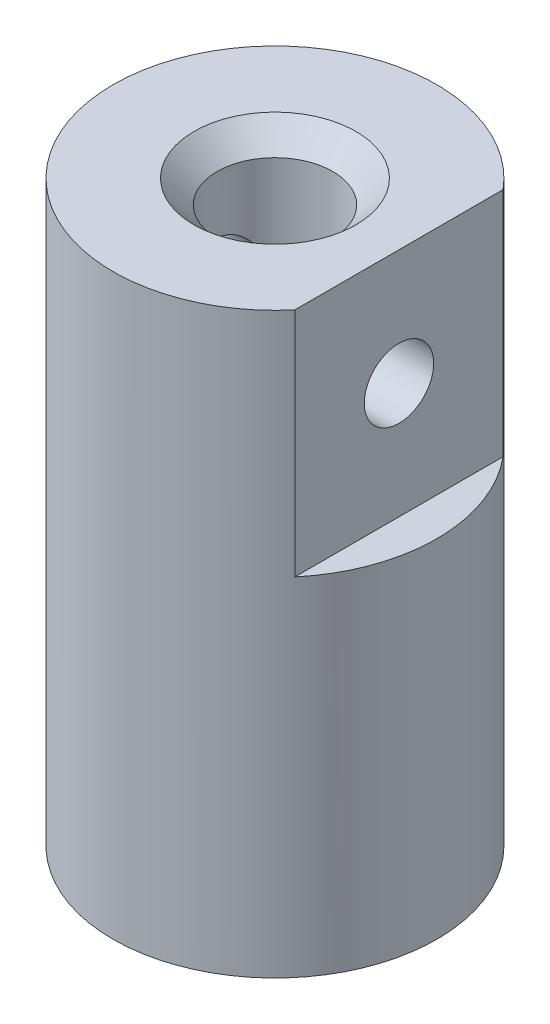
from build123d import *

# Parameters (mm, degrees)
ESQUISSE1_R             = 7
BOSS_EXTRU_1_DEPTH      = 25
ENL_V_MAT_EXTRU_1_REACH = 27
ESQUISSE2_R             = 2.5
CHANFREIN1_SIZE         = 0.5
CHANFREIN2_SIZE         = 1
ENL_V_MAT_EXTRU_2_DEPTH = 10
ESQUISSE4_R             = 1.5
ENL_V_MAT_EXTRU_3_DEPTH = 13.361902647


with BuildPart() as part:
    # Esquisse1 → Boss.-Extru.1 (new body)
    with BuildSketch(Plane(origin=(0, 0, 0), x_dir=(1, 0, 0), z_dir=(0, 1, 0))):
        Circle(ESQUISSE1_R)
    extrude(amount=BOSS_EXTRU_1_DEPTH)

    # Esquisse2 → Enlèv. mat.-Extru.1 (cut, up to next)
    with BuildSketch(Plane(origin=(0, 0, 0), x_dir=(-1, 0, 0), z_dir=(0, -1, 0)), mode=Mode.PRIVATE) as enl_v_mat_extru_1_sk1:
        Circle(ESQUISSE2_R)
    enl_v_mat_extru_1_tool1 = extrude(enl_v_mat_extru_1_sk1.sketch, amount=-ENL_V_MAT_EXTRU_1_REACH, mode=Mode.PRIVATE) & part.part
    add(enl_v_mat_extru_1_tool1.solids().sort_by_distance((0, 0, 0))[0], mode=Mode.SUBTRACT)

    # Chanfrein1
    chanfrein1_edges = [part.edges().sort_by_distance(p)[0] for p in [
        (2.5, 0, 0),
    ]]
    chamfer(chanfrein1_edges, length=CHANFREIN1_SIZE)

    # Chanfrein2
    chanfrein2_edges = [part.edges().sort_by_distance(p)[0] for p in [
        (2.5, 25, 0),
    ]]
    chamfer(chanfrein2_edges, length=CHANFREIN2_SIZE)

    # Esquisse3 → Enlèv. mat.-Extru.2 (cut)
    with BuildSketch(Plane(origin=(0, 25, 0), x_dir=(1, 0, 0), z_dir=(0, 1, 0))):
        Polygon((5.361902647, 48.267833041), (5.361902647, 4.5), (5.361902647, -4.5), (5.361902647, -48.267833041), (92.897568728, -48.267833041), (92.897568728, 48.267833041), align=None)
    extrude(amount=-ENL_V_MAT_EXTRU_2_DEPTH, mode=Mode.SUBTRACT)

    # Esquisse4 → Enlèv. mat.-Extru.3 (cut, through all)
    with BuildSketch(Plane(origin=(5.361902647, 0, 0), x_dir=(0, 0, -1), z_dir=(1, 0, 0))):
        with Locations((0, 20)):
            Circle(ESQUISSE4_R)
    extrude(amount=-ENL_V_MAT_EXTRU_3_DEPTH, mode=Mode.SUBTRACT)


solid = part.part
